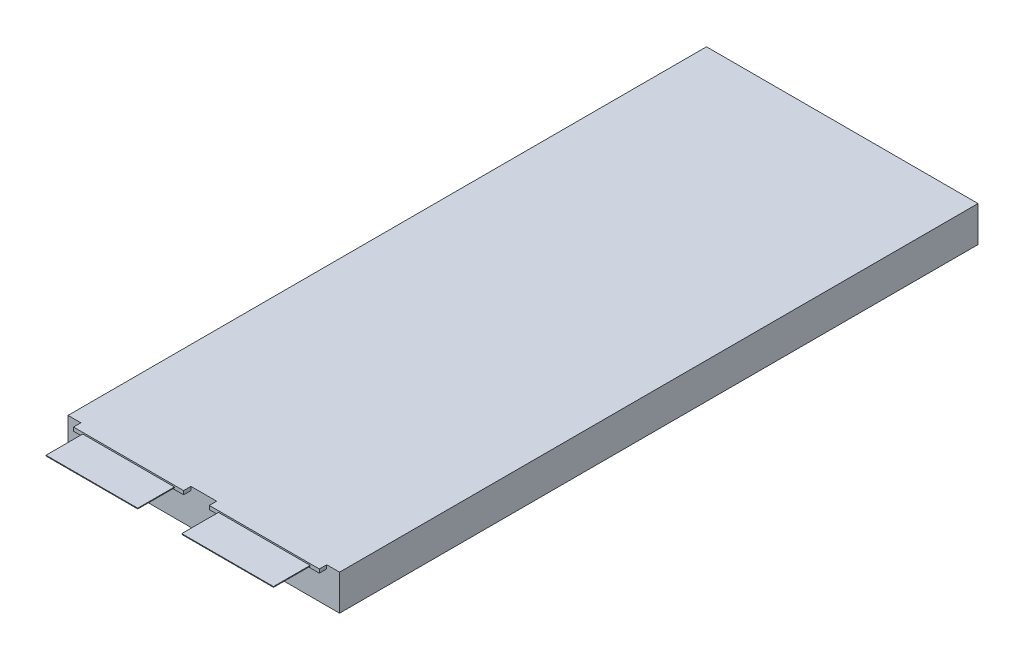
from build123d import *

# Parameters (mm, degrees)
SZKIC1_W                    = 74
SZKIC1_H                    = 9.7
DODANIE_WYCI_GNI_CIE1_DEPTH = 174
DODANIE_WYCI_GNI_CIE2_DEPTH = 2
SZKIC3_W                    = 25
SZKIC3_H                    = 0.2
DODANIE_WYCI_GNI_CIE3_DEPTH = 10
SZKIC4_W                    = 25
SZKIC4_H                    = 0.2
DODANIE_WYCI_GNI_CIE4_DEPTH = 10


with BuildPart() as part:
    # Szkic1 → Dodanie-wyciągnięcie1 (new body)
    with BuildSketch(Plane.XY):
        with Locations((37, -4.85)):
            Rectangle(SZKIC1_W, SZKIC1_H)
    extrude(amount=DODANIE_WYCI_GNI_CIE1_DEPTH)

    # Szkic2 → Dodanie-wyciągnięcie2 (add)
    with BuildSketch(Plane.XY.offset(174)):
        Polygon((3.5, 0), (3.5, -1), (33.5, -1), (33.5, 0), (18.5, 0), align=None)
        Polygon((40.5, 0), (40.5, -1), (70.5, -1), (70.5, 0), (55.5, 0), align=None)
    extrude(amount=DODANIE_WYCI_GNI_CIE2_DEPTH)

    # Szkic3 → Dodanie-wyciągnięcie3 (add)
    with BuildSketch(Plane.XY.offset(176)):
        with Locations((18.5, -0.5)):
            Rectangle(SZKIC3_W, SZKIC3_H)
    extrude(amount=DODANIE_WYCI_GNI_CIE3_DEPTH)

    # Szkic4 → Dodanie-wyciągnięcie4 (add)
    with BuildSketch(Plane.XY.offset(176)):
        with Locations((55.5, -0.5)):
            Rectangle(SZKIC4_W, SZKIC4_H)
    extrude(amount=DODANIE_WYCI_GNI_CIE4_DEPTH)


solid = part.part
